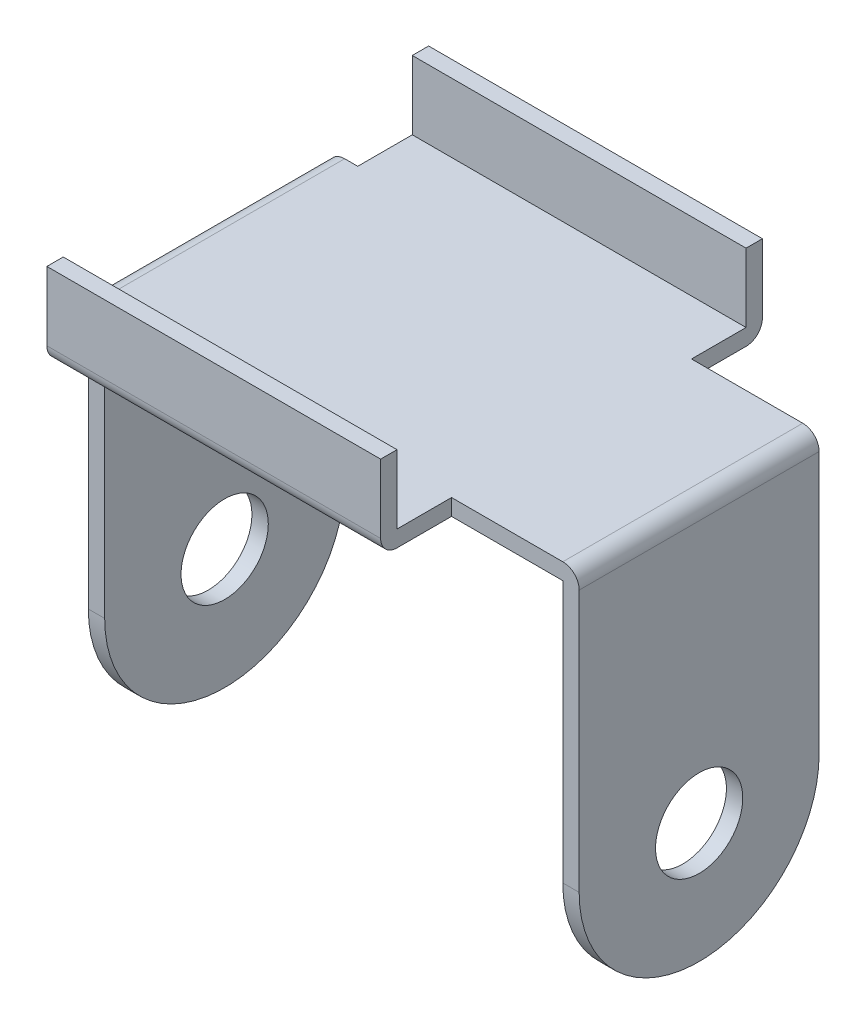
from build123d import *

# Parameters (mm, degrees)
BOSS_EXTRUDE1_DEPTH          = 45
SKETCH2_W                    = 42
SKETCH2_H                    = 41.882656114
CUT_EXTRUDE1_DEPTH           = 23
SKETCH3_W                    = 30.6
SKETCH3_H                    = 1.5
BOSS_EXTRUDE2_DEPTH          = 6.5
SKETCH4_W                    = 30.6
SKETCH4_H                    = 1.5
BOSS_EXTRUDE3_DEPTH          = 6.3
SKETCH5_W                    = 30.6
SKETCH5_H                    = 1.5
BOSS_EXTRUDE4_DEPTH          = 6.5
SKETCH6_W                    = 30.6
SKETCH6_H                    = 1.5
BOSS_EXTRUDE5_DEPTH          = 6.3
F_8_0_8_DIAMETER_HOLE1_D     = 8
F_8_0_8_DIAMETER_HOLE1_DEPTH = 1.5
F_8_0_8_DIAMETER_HOLE2_D     = 8
F_8_0_8_DIAMETER_HOLE2_DEPTH = 1.5
FILLET1_R                    = 1.5


with BuildPart() as part:
    # Sketch1 → Boss-Extrude1 (new body)
    with BuildSketch(Plane(origin=(-22.5, 0, 0), x_dir=(0, -1, 0), z_dir=(-1, 0, 0))):
        with BuildLine():
            Line((-25.5, -11), (0, -11))
            ThreePointArc((0, -11), (11, 0), (0, 11))
            Line((0, 11), (-25.5, 11))
            Line((-25.5, 11), (-25.5, -11))
        make_face()
    extrude(amount=-BOSS_EXTRUDE1_DEPTH)

    # Sketch2 → Cut-Extrude1 (cut, through all)
    with BuildSketch(Plane.XY.offset(11)):
        with Locations((0, 3.058671943)):
            Rectangle(SKETCH2_W, SKETCH2_H)
    extrude(amount=-CUT_EXTRUDE1_DEPTH, mode=Mode.SUBTRACT)

    # Sketch3 → Boss-Extrude2 (add)
    with BuildSketch(Plane(origin=(0, 0, -11), x_dir=(-1, 0, 0), z_dir=(0, 0, -1))):
        with Locations((4.5, 24.75)):
            Rectangle(SKETCH3_W, SKETCH3_H)
    extrude(amount=BOSS_EXTRUDE2_DEPTH)

    # Sketch4 → Boss-Extrude3 (add)
    with BuildSketch(Plane(origin=(0, 25.5, 0), x_dir=(-1, 0, 0), z_dir=(0, 1, 0))):
        with Locations((4.5, -16.75)):
            Rectangle(SKETCH4_W, SKETCH4_H)
    extrude(amount=BOSS_EXTRUDE3_DEPTH)

    # Sketch5 → Boss-Extrude4 (add)
    with BuildSketch(Plane.XY.offset(11)):
        with Locations((-4.5, 24.75)):
            Rectangle(SKETCH5_W, SKETCH5_H)
    extrude(amount=BOSS_EXTRUDE4_DEPTH)

    # Sketch6 → Boss-Extrude5 (add)
    with BuildSketch(Plane(origin=(0, 25.5, 0), x_dir=(-1, 0, 0), z_dir=(0, 1, 0))):
        with Locations((4.5, 16.75)):
            Rectangle(SKETCH6_W, SKETCH6_H)
    extrude(amount=BOSS_EXTRUDE5_DEPTH)

    # Ø8.0 (8) Diameter Hole1
    with Locations(Plane.ZY.offset(-21)):
        with Locations((0, 0)):
            Hole(F_8_0_8_DIAMETER_HOLE1_D / 2, depth=F_8_0_8_DIAMETER_HOLE1_DEPTH)

    # Ø8.0 (8) Diameter Hole2
    with Locations(Plane(origin=(-21, 0, 0), x_dir=(0, 0, -1), z_dir=(1, 0, 0))):
        with Locations((0, 0)):
            Hole(F_8_0_8_DIAMETER_HOLE2_D / 2, depth=F_8_0_8_DIAMETER_HOLE2_DEPTH)

    # Fillet1
    fillet1_edges = [part.edges().sort_by_distance(p)[0] for p in [
        (-4.5, 24, -17.5),
        (22.5, 25.5, 0),
        (-22.5, 25.5, 0),
        (-4.5, 24, 17.5),
    ]]
    fillet(fillet1_edges, radius=FILLET1_R)


solid = part.part
